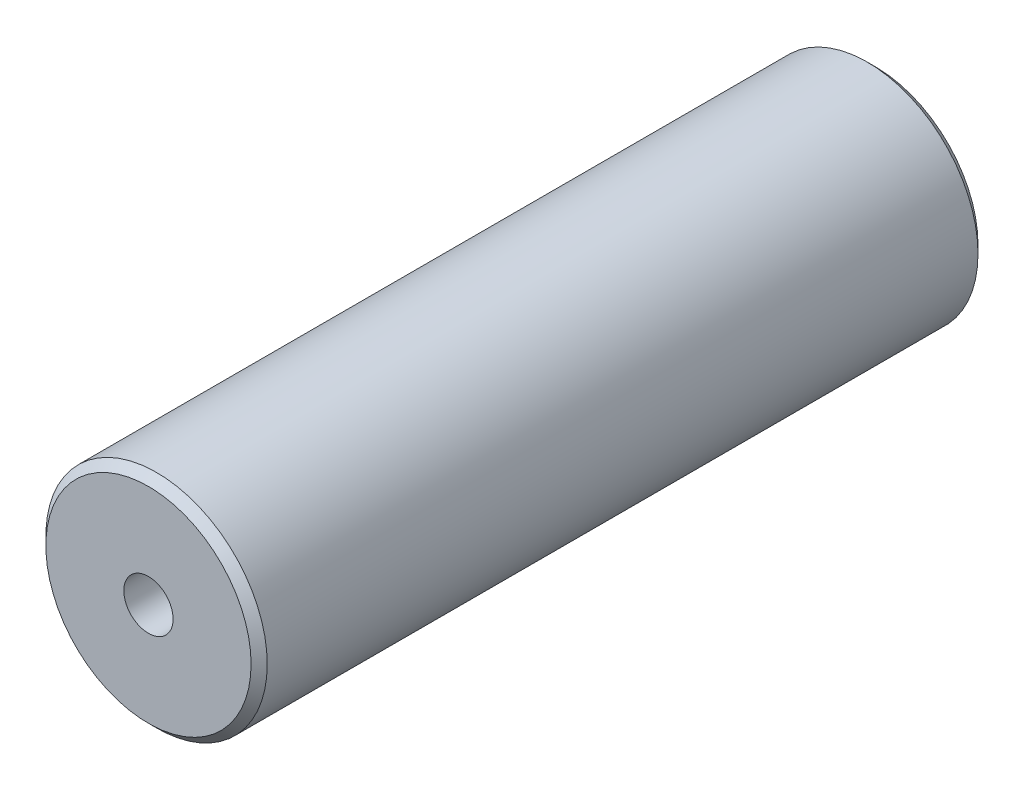
from build123d import *

# Parameters (mm, degrees)
SKETCH1_R           = 13.706386673
SKETCH1_R_2         = 3.05
BOSS_EXTRUDE1_DEPTH = 90
CHAMFER1_SIZE       = 1


with BuildPart() as part:
    # Sketch1 → Boss-Extrude1 (new body)
    with BuildSketch(Plane.XY):
        Circle(SKETCH1_R)
        Circle(SKETCH1_R_2, mode=Mode.SUBTRACT)
    extrude(amount=BOSS_EXTRUDE1_DEPTH)

    # Chamfer1
    chamfer1_edges = [part.edges().sort_by_distance(p)[0] for p in [
        (-13.706386673, 0, 0),
        (-13.706386673, 0, 90),
    ]]
    chamfer(chamfer1_edges, length=CHAMFER1_SIZE)


solid = part.part
